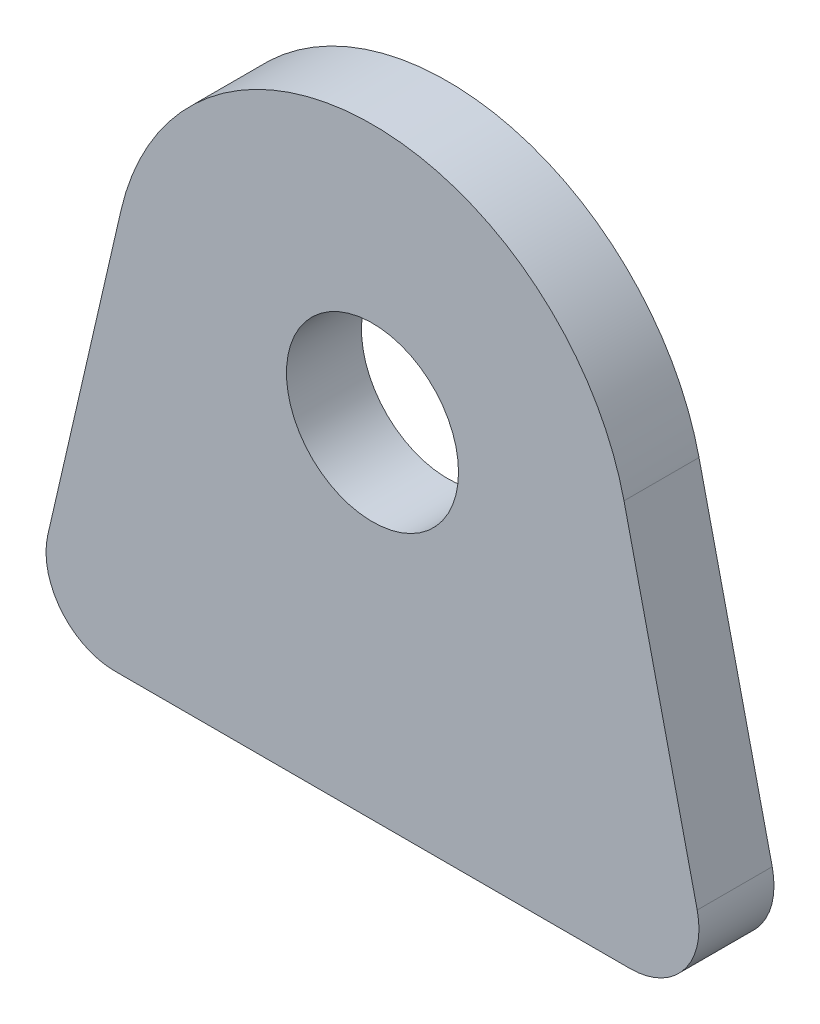
from build123d import *

# Parameters (mm, degrees)
SKETCH1_R           = 3.175
BOSS_EXTRUDE1_DEPTH = 1.3843


with BuildPart() as part:
    # Sketch1 → Boss-Extrude1 (new body, symmetric)
    with BuildSketch(Plane.XY):
        with BuildLine():
            Line((-9.281911907, 14.838161907), (-11.983546213, 3.110176509))
            ThreePointArc((-11.983546213, 3.110176509), (-11.495811318, 0.958331313), (-9.508369704, 0))
            Line((-9.508369704, 0), (9.508369704, 0))
            ThreePointArc((9.508369704, 0), (11.495811318, 0.958331313), (11.983546213, 3.110176509))
            Line((11.983546213, 3.110176509), (9.281911907, 14.838161907))
            ThreePointArc((9.281911907, 14.838161907), (0, 22.225), (-9.281911907, 14.838161907))
        make_face()
        with Locations((0, 12.7)):
            Circle(SKETCH1_R, mode=Mode.SUBTRACT)
    extrude(amount=BOSS_EXTRUDE1_DEPTH, both=True)


solid = part.part
